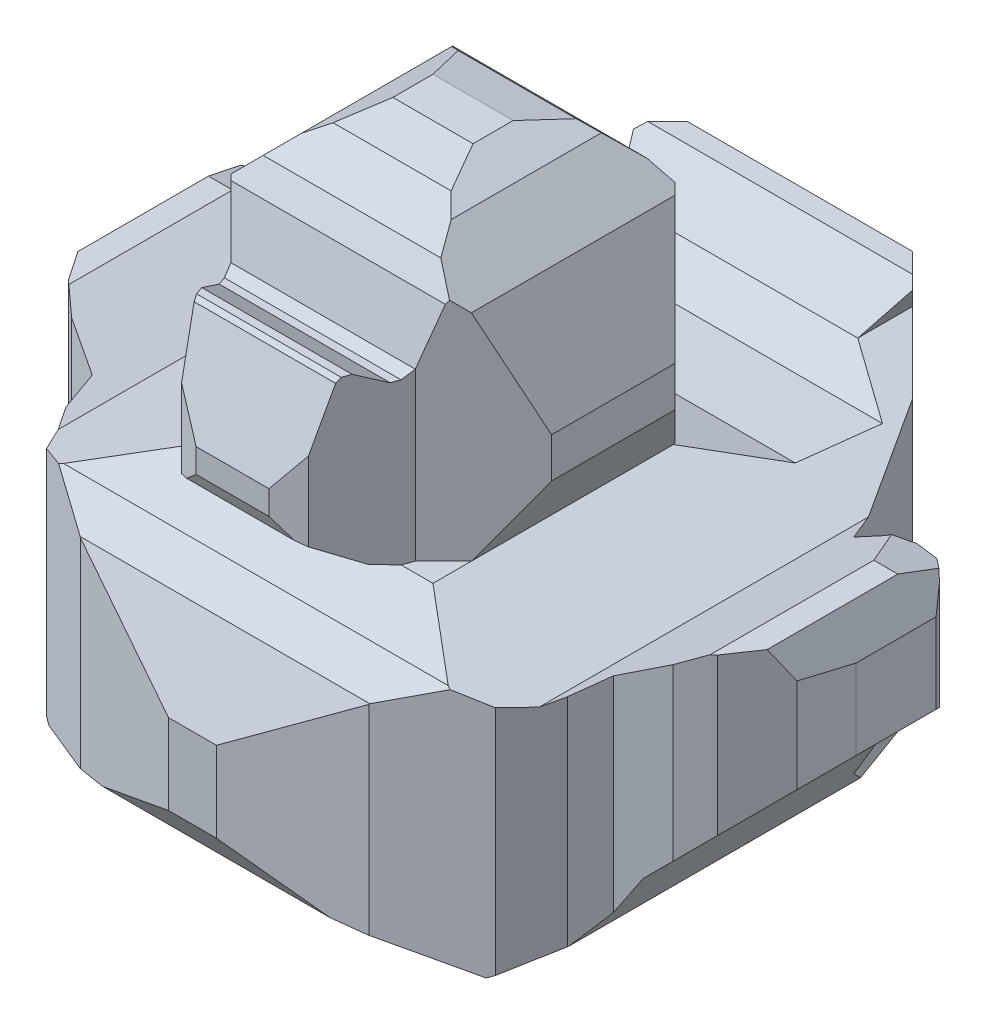
from build123d import *

# Parameters (mm, degrees)
BOSS_EXTRUDE1_DEPTH     = 4
CUT_EXTRUDE2_DEPTH      = 4.5
CUT_EXTRUDE2_DEPTH_BACK = 1
CUT_EXTRUDE3_DEPTH      = 3.25
CUT_EXTRUDE3_DEPTH_BACK = 3.25
CUT_EXTRUDE4_DEPTH      = 1.75


with BuildPart() as part:
    # Sketch1 → Boss-Extrude1 (new body)
    with BuildSketch(Plane.XY):
        Polygon((1.25, 0), (-1.25, 0), (-1.566987298, 0.183012702), (-1.75, 0.5), (-2.25, 1), (-2.25, 1.5), (-2.15, 1.75), (-2, 1.75), (-1.5, 1.5), (-0.75, 1.75), (-1, 2.183012702), (-1, 2.433012702), (-0.75, 3.091506351), (-0.466506351, 3.375), (-0.25, 3.5), (0.25, 3.5), (0.466506351, 3.375), (0.75, 3.091506351), (1, 2.433012702), (1, 2.183012702), (0.75, 1.75), (1.5, 1.5), (2, 1.75), (2.15, 1.75), (2.25, 1.5), (2.25, 1), (1.75, 0.5), (1.566987298, 0.183012702), align=None)
    extrude(amount=-BOSS_EXTRUDE1_DEPTH)

    # Sketch2 → Cut-Extrude2 (cut, two sides)
    with BuildSketch(Plane(origin=(0, 0, 0), x_dir=(1, 0, 0), z_dir=(0, 1, 0))) as cut_extrude2_sk:
        Polygon((-2.25, 4), (-0.125, 4), (-0.625, 3.866025404), (-1.125, 3.366025404), (-1.375, 2.933012702), (-1.625, 2.5), (-1.8, 2.515310516), (-1.95, 2.569906051), (-2.1, 2.543457004), (-2.2, 2.459547041), (-2.25, 2.388139641), align=None)
        Polygon((2.25, 4), (2.25, 2.388139641), (2.2, 2.459547041), (2.1, 2.543457004), (1.95, 2.569906051), (1.8, 2.515310516), (1.625, 2.5), (1.375, 2.933012702), (1.125, 3.366025404), (0.625, 3.866025404), (0.125, 4), align=None)
        Polygon((2.25, 0), (0.15, 0), (0.9, 0.200961894), (1.4, 0.489637029), (1.56467423, 0.774861163), (1.625, 1), (1.875, 1.121015931), (2.025, 1.250629304), (2.225, 1.545251417), (2.25, 1.888139641), align=None)
        Polygon((-2.25, 0), (-2.25, 1.888139641), (-2.225, 1.545251417), (-2.025, 1.250629304), (-1.875, 1.121015931), (-1.625, 1), (-1.56467423, 0.774861163), (-1.4, 0.489637029), (-0.9, 0.200961894), (-0.15, 0), align=None)
    extrude(amount=CUT_EXTRUDE2_DEPTH, mode=Mode.SUBTRACT)
    extrude(cut_extrude2_sk.sketch, amount=-CUT_EXTRUDE2_DEPTH_BACK, mode=Mode.SUBTRACT)

    # Sketch3 → Cut-Extrude3 (cut, two sides)
    with BuildSketch(Plane(origin=(0, 0, 0), x_dir=(0, 0, -1), z_dir=(1, 0, 0))) as cut_extrude3_sk:
        Polygon((0.75, 0), (0.5, 0.05), (0.15, 0.223056275), (0, 0.448056275), (0, 0), align=None)
        Polygon((0.75, 1.75), (0.395308416, 1.6), (0.202788783, 1.45), (0, 0.95), (0, 3.5), (1.5, 3.5), (1.245096189, 3.43169873), (0.995096189, 3.287361163), (0.908493649, 3.137361163), (0.814711432, 2.787361163), (0.75, 2.75), (0.7, 2.75), (0.526794919, 2.85), (0.476794919, 2.85), (0.451794919, 2.825), (0.25, 2.25), (0.25, 2.1), (0.3, 1.999431174), (0.6, 1.800377785), align=None)
        Polygon((1.75, 3.5), (2.025, 3.43169873), (2.229006351, 3.235048095), (2.375164424, 2.992297439), (2.5, 2.55842438), (2.504589784, 2.30842438), (2.460345023, 2.13028261), (2.25, 1.75), (2.65, 1.63007538), (3.15, 1.615328853), (3.4, 1.75), (3.665194664, 2), (3.788675135, 2), (3.933012702, 1.75), (4, 1.5), (4, 3.5), align=None)
        Polygon((3.257772228, 0), (4, 0), (4, 1.25), (3.876460197, 0.75), (3.738574291, 0.5), align=None)
    extrude(amount=CUT_EXTRUDE3_DEPTH, mode=Mode.SUBTRACT)
    extrude(cut_extrude3_sk.sketch, amount=-CUT_EXTRUDE3_DEPTH_BACK, mode=Mode.SUBTRACT)

    # Sketch4 → Cut-Extrude4 (cut)
    with BuildSketch(Plane(origin=(0, 3.5, 0), x_dir=(1, 0, 0), z_dir=(0, 1, 0))):
        Polygon((1, 2.51), (0.5, 2.51), (1, 2.01), align=None)
        Polygon((-1, 2.51), (-0.5, 2.51), (-1, 2.01), align=None)
        Polygon((0.575, 0.814711432), (1, 1.239711432), (1, 0.202788783), (0.125, 0.202788783), (0.395706228, 0.327788783), align=None)
        Polygon((-0.575, 0.814711432), (-1, 1.239711432), (-1, 0.202788783), (-0.125, 0.202788783), (-0.395706228, 0.327788783), align=None)
    extrude(amount=-CUT_EXTRUDE4_DEPTH, mode=Mode.SUBTRACT)


solid = part.part
